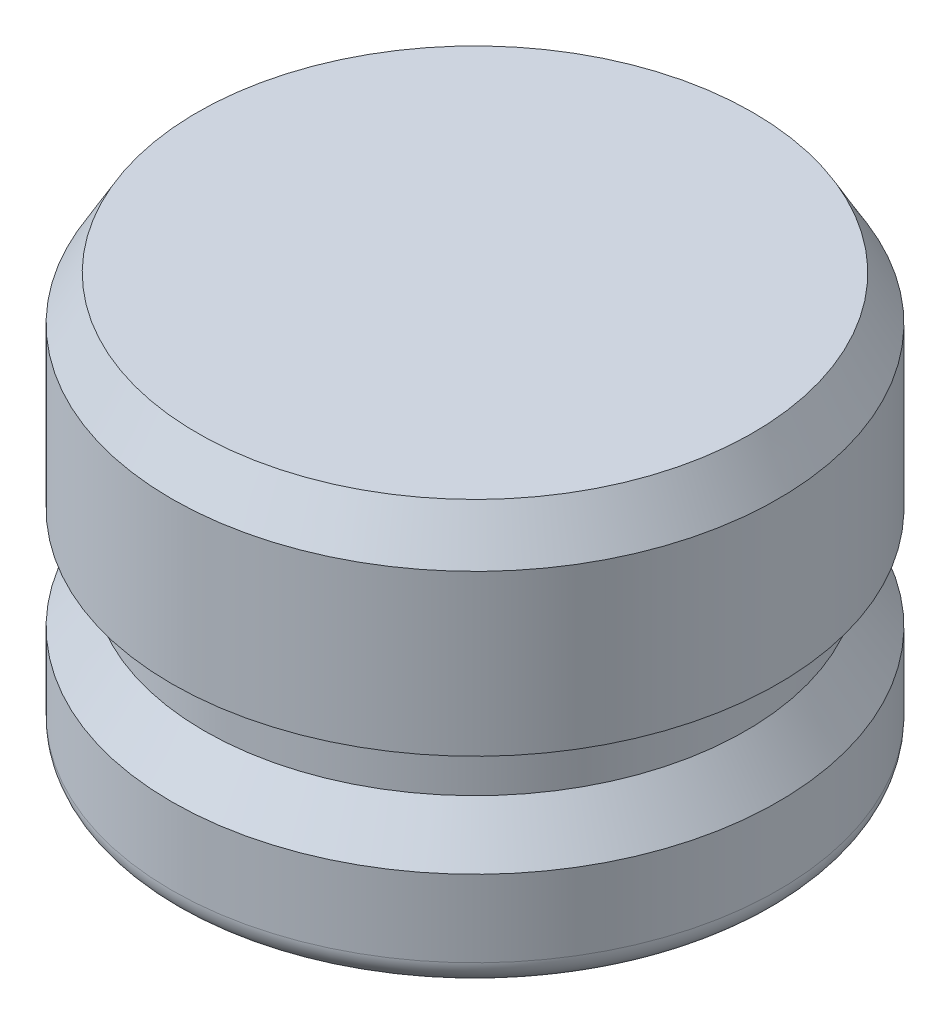
from build123d import *

# Parameters (mm, degrees)
FILLET1_R      = 0.79375
CHAMFER1_SIZE  = 0.79375
CHAMFER1_SIZE2 = 1.374815329


with BuildPart() as part:
    # Sketch1 → Revolve1 (revolve)
    with BuildSketch(Plane.XY):
        Polygon((0, 0), (-9.4234, 0), (-9.4234, 3.175), (-8.4074, 4.572), (-8.4074, 6.35), (-9.4234, 6.35), (-9.4234, 12.7), (0, 12.7), align=None)
    revolve(axis=Axis((0, 0, 0), (0, 1, 0)))

    # Fillet1
    fillet1_edges = [part.edges().sort_by_distance(p)[0] for p in [
        (9.4234, 0, 0),
    ]]
    fillet(fillet1_edges, radius=FILLET1_R)

    # Chamfer1
    chamfer1_edges = [part.edges().sort_by_distance(p)[0] for p in [
        (9.4234, 12.7, 0),
    ]]
    chamfer1_side = [part.faces().sort_by_distance(p)[0] for p in [
        (0, 12.7, 0),
    ]]
    chamfer(chamfer1_edges, length=CHAMFER1_SIZE, length2=CHAMFER1_SIZE2, reference=chamfer1_side[0])


solid = part.part
